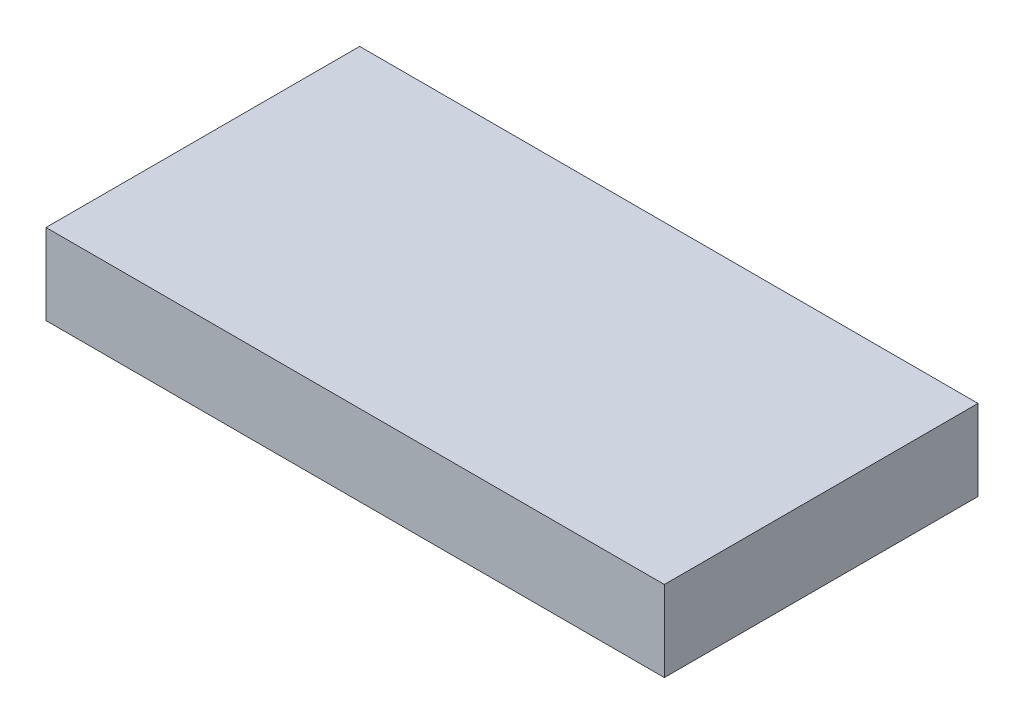
from build123d import *

# Parameters (mm, degrees)
SKETCH_4_W      = 69
SKETCH_4_H      = 35
EXTRUDE_1_DEPTH = 9


with BuildPart() as part:
    # 草图4 → 凸台-拉伸1 (new body)
    with BuildSketch(Plane(origin=(0, 0, 0), x_dir=(1, 0, 0), z_dir=(0, 1, 0))):
        with Locations((8.806054065, -9.267987481)):
            Rectangle(SKETCH_4_W, SKETCH_4_H)
    extrude(amount=-EXTRUDE_1_DEPTH)


solid = part.part
